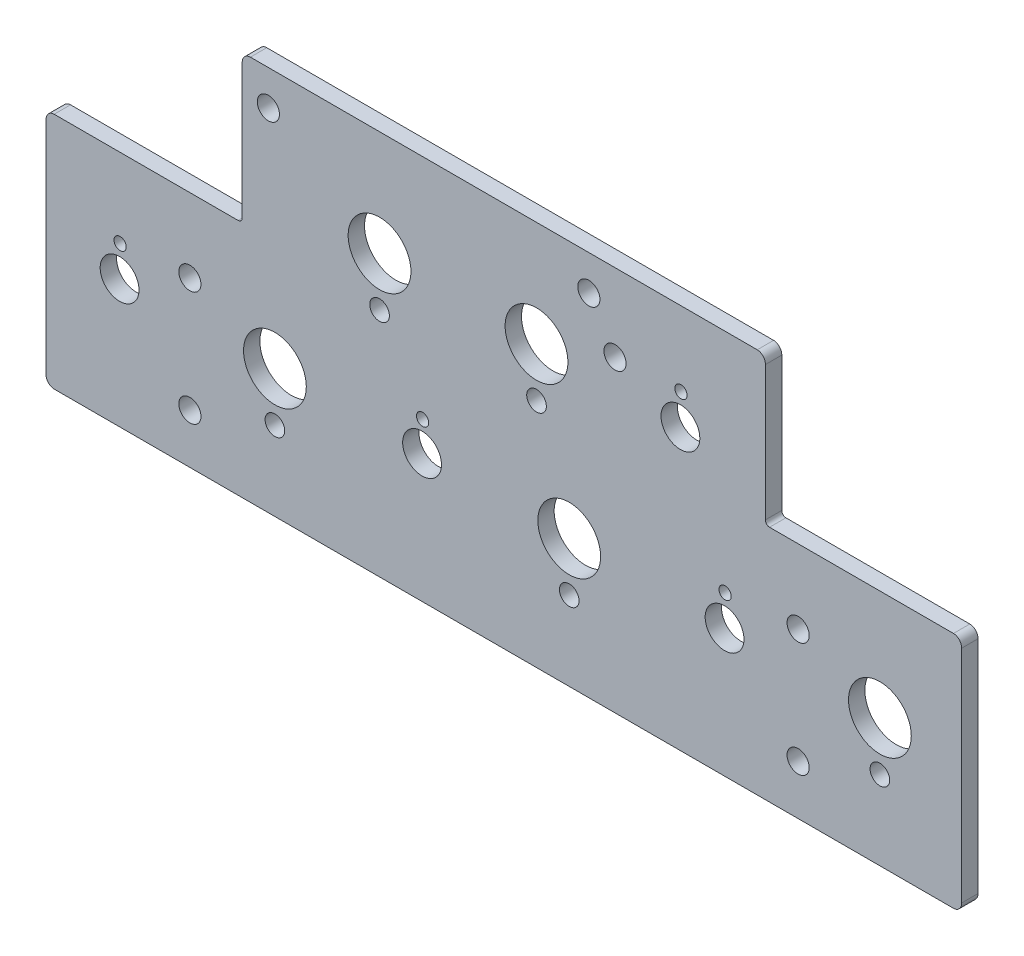
from build123d import *

# Parameters (mm, degrees)
BOSS_EXTRUDE1_DEPTH   = 3.175
SKETCH2_R             = 3.7703125
CUT_EXTRUDE1_DEPTH    = 4.1750001
SKETCH4_R             = 6.096
SKETCH4_R_2           = 1.905
CUT_EXTRUDE2_DEPTH    = 4.1750001
F_6_CLEARANCE_HOLE1_D = 4.3053
SKETCH7_R             = 1.190625
CUT_EXTRUDE3_DEPTH    = 4.1750001


with BuildPart() as part:
    # Sketch1 → Boss-Extrude1 (new body)
    with BuildSketch(Plane.XY):
        with BuildLine():
            Line((-51.59375, 5.432306697), (-87.3125, 5.432306697))
            add(Edge.make_bspline(
                [(-87.3125, 5.432306697), (-88.9, 5.432306697), (-88.9, 3.742924483)],
                knots=[3.141592654, 3.141592654, 3.141592654, 4.71238898, 4.71238898, 4.71238898], degree=2, weights=[1, 0.707106781, 1]))
            Line((-88.9, 3.742924483), (-88.9, -39.099808459))
            add(Edge.make_bspline(
                [(-88.9, -39.099808459), (-88.9, -40.789190673), (-87.3125, -40.789190673)],
                knots=[1.570796327, 1.570796327, 1.570796327, 3.141592654, 3.141592654, 3.141592654], degree=2, weights=[1, 0.707106781, 1]))
            Line((-87.3125, -40.789190673), (87.3125, -40.789190673))
            add(Edge.make_bspline(
                [(87.3125, -40.789190673), (88.9, -40.789190673), (88.9, -39.099808459)],
                knots=[3.141592654, 3.141592654, 3.141592654, 4.71238898, 4.71238898, 4.71238898], degree=2, weights=[1, 0.707106781, 1]))
            Line((88.9, -39.099808459), (88.9, 3.742924483))
            add(Edge.make_bspline(
                [(88.9, 3.742924483), (88.9, 5.432306697), (87.3125, 5.432306697)],
                knots=[1.570796327, 1.570796327, 1.570796327, 3.141592654, 3.141592654, 3.141592654], degree=2, weights=[1, 0.707106781, 1]))
            Line((87.3125, 5.432306697), (51.59375, 5.432306697))
            add(Edge.make_bspline(
                [(50.8, 6.276997804), (50.8, 5.432306697), (51.59375, 5.432306697)],
                knots=[4.71238898, 4.71238898, 4.71238898, 6.283185307, 6.283185307, 6.283185307], degree=2, weights=[1, 0.707106781, 1]))
            Line((50.8, 6.276997804), (50.8, 32.394846829))
            add(Edge.make_bspline(
                [(50.8, 32.394846829), (50.8, 34.084229043), (49.2125, 34.084229043)],
                knots=[4.71238898, 4.71238898, 4.71238898, 6.283185307, 6.283185307, 6.283185307], degree=2, weights=[1, 0.707106781, 1]))
            Line((49.2125, 34.084229043), (-49.2125, 34.084229043))
            add(Edge.make_bspline(
                [(-49.2125, 34.084229043), (-50.8, 34.084229043), (-50.8, 32.394846829)],
                knots=[0, 0, 0, 1.570796327, 1.570796327, 1.570796327], degree=2, weights=[1, 0.707106781, 1]))
            Line((-50.8, 32.394846829), (-50.8, 6.276997804))
            add(Edge.make_bspline(
                [(-51.59375, 5.432306697), (-50.8, 5.432306697), (-50.8, 6.276997804)],
                knots=[0, 0, 0, 1.570796327, 1.570796327, 1.570796327], degree=2, weights=[1, 0.707106781, 1]))
        make_face()
    extrude(amount=BOSS_EXTRUDE1_DEPTH)

    # Sketch2 → Cut-Extrude1 (cut, through all)
    with BuildSketch(Plane.XY.offset(3.175)):
        with Locations((42.8625, -15.909796167)):
            Circle(SKETCH2_R)
        with Locations((-15.875, -15.909796167)):
            Circle(SKETCH2_R)
        with Locations((-74.6125, -15.909796167)):
            Circle(SKETCH2_R)
        with Locations((34.29, 13.617703833)):
            Circle(SKETCH2_R)
    extrude(amount=-CUT_EXTRUDE1_DEPTH, mode=Mode.SUBTRACT)

    # Sketch4 → Cut-Extrude2 (cut, through all)
    with BuildSketch(Plane.XY.offset(3.175)):
        with Locations((73.025, -15.909796167)):
            Circle(SKETCH4_R)
        with Locations((12.7, -15.909796167)):
            Circle(SKETCH4_R)
        with Locations((-44.45, -15.909796167)):
            Circle(SKETCH4_R)
        with Locations((-24.13, 13.617703833)):
            Circle(SKETCH4_R)
        with Locations((6.35, 13.617703833)):
            Circle(SKETCH4_R)
        with Locations((73.025, -25.434796167)):
            Circle(SKETCH4_R_2)
        with Locations((12.7, -25.434796167)):
            Circle(SKETCH4_R_2)
        with Locations((-44.45, -25.434796167)):
            Circle(SKETCH4_R_2)
        with Locations((6.35, 4.092703833)):
            Circle(SKETCH4_R_2)
        with Locations((-24.13, 4.092703833)):
            Circle(SKETCH4_R_2)
    extrude(amount=-CUT_EXTRUDE2_DEPTH, mode=Mode.SUBTRACT)

    # #6 Clearance Hole1 (through all)
    with Locations(Plane.XY.offset(3.175)):
        with Locations((-45.72, 27.270203833), (16.51, 27.270203833), (21.59, 19.015203833), (57.15, -8.924796167), (57.15, -31.149796167), (-60.96, -31.149796167), (-60.96, -8.924796167)):
            Hole(F_6_CLEARANCE_HOLE1_D / 2)

    # Sketch7 → Cut-Extrude3 (cut, through all)
    with BuildSketch(Plane.XY.offset(3.175)):
        with Locations((42.967003171, -9.910706312)):
            Circle(SKETCH7_R)
        with Locations((-15.773980268, -10.110675974)):
            Circle(SKETCH7_R)
        with Locations((-74.507996829, -9.910706312)):
            Circle(SKETCH7_R)
        with Locations((34.394503171, 19.616793688)):
            Circle(SKETCH7_R)
    extrude(amount=-CUT_EXTRUDE3_DEPTH, mode=Mode.SUBTRACT)


solid = part.part
